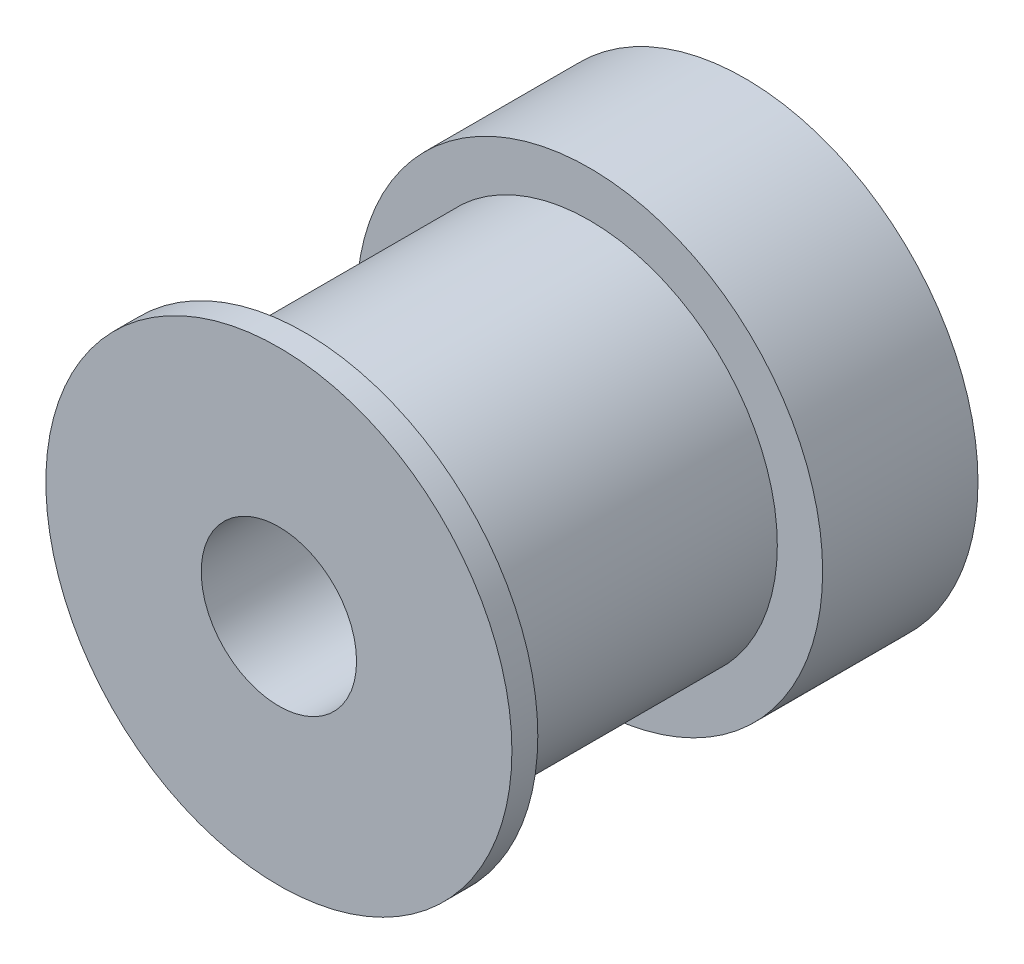
from build123d import *

# Parameters (mm, degrees)
SKETCH1_R           = 9
SKETCH1_R_2         = 3
BOSS_EXTRUDE1_DEPTH = 6
SKETCH2_R           = 7.25
SKETCH2_R_2         = 3
BOSS_EXTRUDE2_DEPTH = 11
SKETCH3_R           = 9
SKETCH3_R_2         = 3
BOSS_EXTRUDE3_DEPTH = 1
SKETCH4_R           = 1.5
CUT_EXTRUDE1_DEPTH  = 10


with BuildPart() as part:
    # Sketch1 → Boss-Extrude1 (new body)
    with BuildSketch(Plane.XY):
        Circle(SKETCH1_R)
        Circle(SKETCH1_R_2, mode=Mode.SUBTRACT)
    extrude(amount=BOSS_EXTRUDE1_DEPTH)

    # Sketch2 → Boss-Extrude2 (add)
    with BuildSketch(Plane.XY.offset(6)):
        Circle(SKETCH2_R)
        Circle(SKETCH2_R_2, mode=Mode.SUBTRACT)
    extrude(amount=BOSS_EXTRUDE2_DEPTH)

    # Sketch3 → Boss-Extrude3 (add)
    with BuildSketch(Plane.XY.offset(17)):
        Circle(SKETCH3_R)
        Circle(SKETCH3_R_2, mode=Mode.SUBTRACT)
    extrude(amount=BOSS_EXTRUDE3_DEPTH)

    # Sketch4 → Cut-Extrude1 (cut, through all)
    with BuildSketch(Plane(origin=(0, 0, 0), x_dir=(1, 0, 0), z_dir=(0, 1, 0))):
        with Locations((0, -4)):
            Circle(SKETCH4_R)
    extrude(amount=-CUT_EXTRUDE1_DEPTH, mode=Mode.SUBTRACT)


solid = part.part
